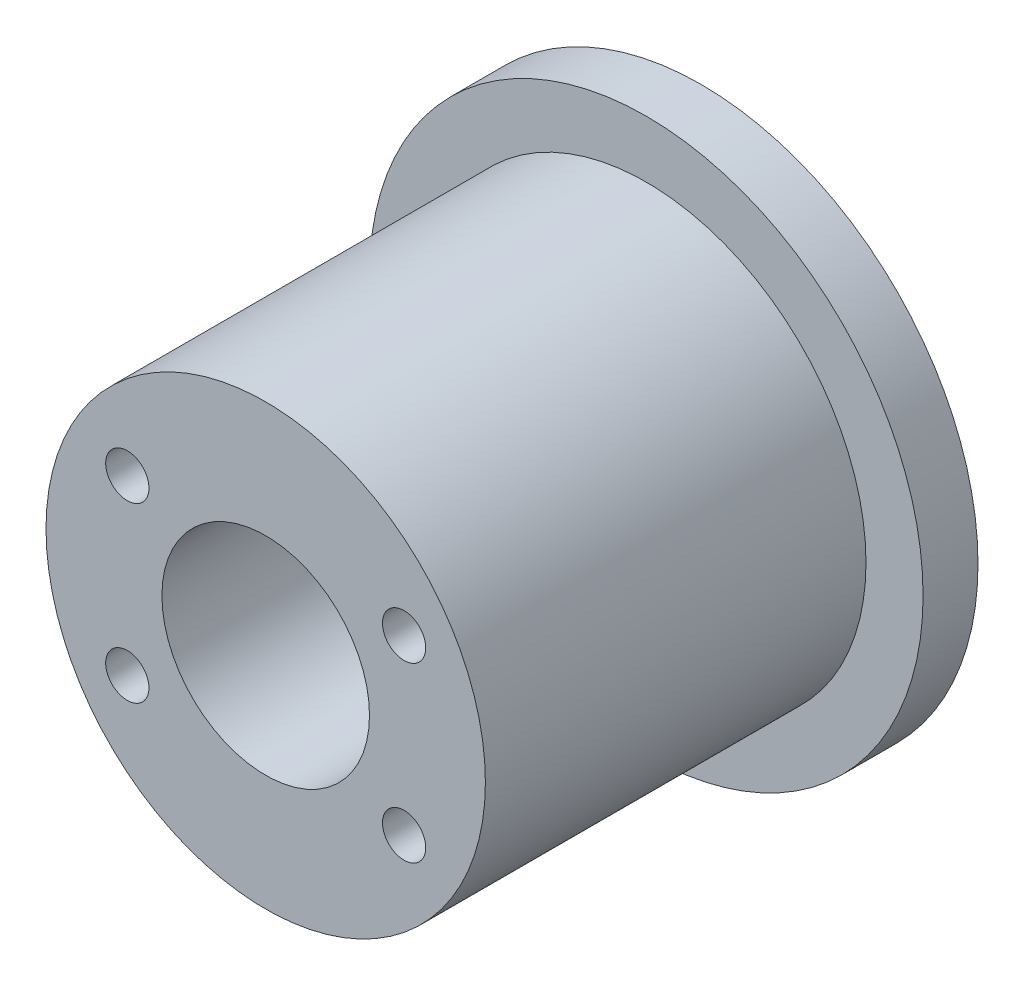
from build123d import *

# Parameters (mm, degrees)
SKETCH2_R                 = 12.7
SKETCH2_R_2               = 6
BOSS_EXTRUDE1_DEPTH       = 11
SKETCH3_R                 = 16
SKETCH3_R_2               = 6
BOSS_EXTRUDE2_DEPTH       = 3.175
M3X0_5_TAPPED_HOLE1_D     = 2.5
M3X0_5_TAPPED_HOLE1_DEPTH = 15
M3X0_5_TAPPED_HOLE1_TIP   = 0.751075774


with BuildPart() as part:
    # Sketch2 → Boss-Extrude1 (new body, symmetric)
    with BuildSketch(Plane.XY):
        Circle(SKETCH2_R)
        Circle(SKETCH2_R_2, mode=Mode.SUBTRACT)
    extrude(amount=BOSS_EXTRUDE1_DEPTH, both=True)

    # Sketch3 → Boss-Extrude2 (add)
    with BuildSketch(Plane(origin=(0, 0, -11), x_dir=(-1, 0, 0), z_dir=(0, 0, -1))):
        Circle(SKETCH3_R)
        Circle(SKETCH3_R_2, mode=Mode.SUBTRACT)
    extrude(amount=BOSS_EXTRUDE2_DEPTH)

    # M3x0.5 Tapped Hole1
    with Locations(Plane.XY.offset(11)):
        with Locations((-8, 5), (-8, -5), (8, -5), (8, 5)):
            Hole(M3X0_5_TAPPED_HOLE1_D / 2, depth=M3X0_5_TAPPED_HOLE1_DEPTH)
            with Locations((0, 0, -(M3X0_5_TAPPED_HOLE1_DEPTH + M3X0_5_TAPPED_HOLE1_TIP / 2))):  # 118° drill point
                Cone(0, M3X0_5_TAPPED_HOLE1_D / 2, M3X0_5_TAPPED_HOLE1_TIP, mode=Mode.SUBTRACT)


solid = part.part
